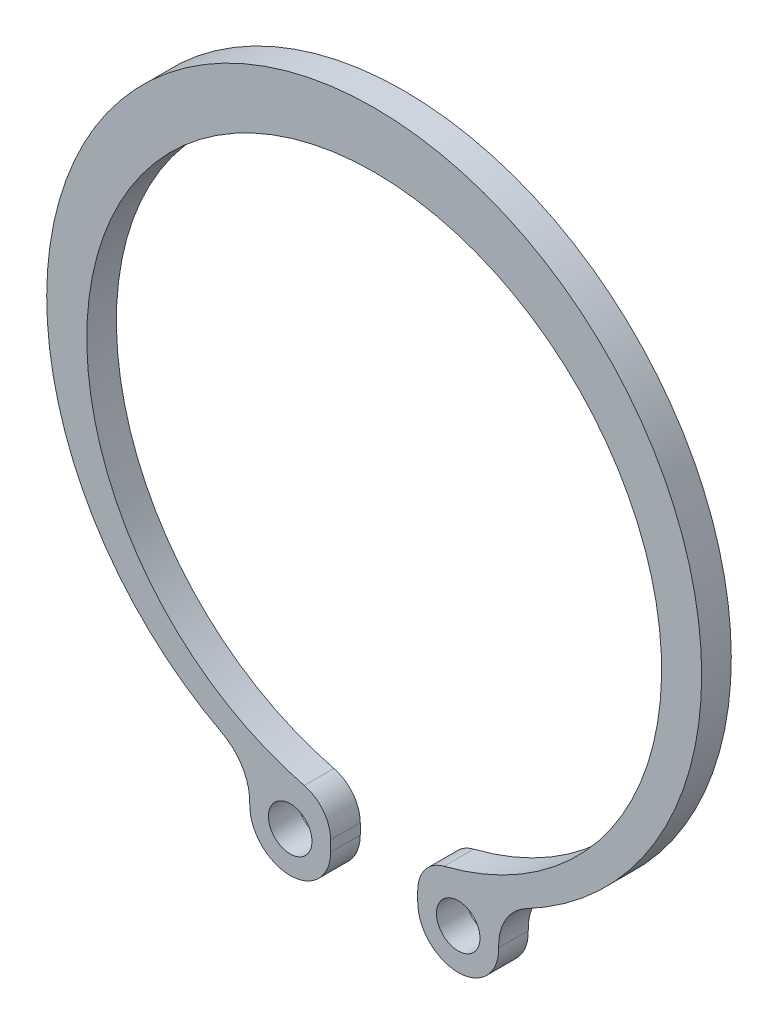
from build123d import *

# Parameters (mm, degrees)
SKETCH_1_R      = 1.25
EXTRUDE_1_DEPTH = 1.7


with BuildPart() as part:
    # Эскиз1 → Бобышка-Вытянуть1 (new body)
    with BuildSketch(Plane.XY):
        with BuildLine():
            Line((-2.5, -19.461432513), (-2.5, -18.844358445))
            ThreePointArc((-2.5, -18.844358445), (-2.923140309, -17.614109074), (-4.013513514, -16.904427802))
            ThreePointArc((-4.013513514, -16.904427802), (0, 15.6), (4.013513514, -16.904427802))
            ThreePointArc((4.013513514, -16.904427802), (2.923140309, -17.614109074), (2.5, -18.844358445))
            Line((2.5, -18.844358445), (2.5, -19.461432513))
            ThreePointArc((2.5, -19.461432513), (4.858226013, -21.783514339), (7.14360974, -19.389706671))
            ThreePointArc((7.14360974, -19.389706671), (7.550732033, -17.785627188), (8.746465933, -16.641494334))
            ThreePointArc((8.746465933, -16.641494334), (0, 18.8), (-8.746465933, -16.641494334))
            ThreePointArc((-8.746465933, -16.641494334), (-7.550732033, -17.785627188), (-7.14360974, -19.389706671))
            ThreePointArc((-7.14360974, -19.389706671), (-4.858226013, -21.783514339), (-2.5, -19.461432513))
        make_face()
        with Locations((-4.822358814, -19.461432513)):
            Circle(SKETCH_1_R, mode=Mode.SUBTRACT)
        with Locations((4.822358814, -19.461432513)):
            Circle(SKETCH_1_R, mode=Mode.SUBTRACT)
    extrude(amount=EXTRUDE_1_DEPTH)


solid = part.part
